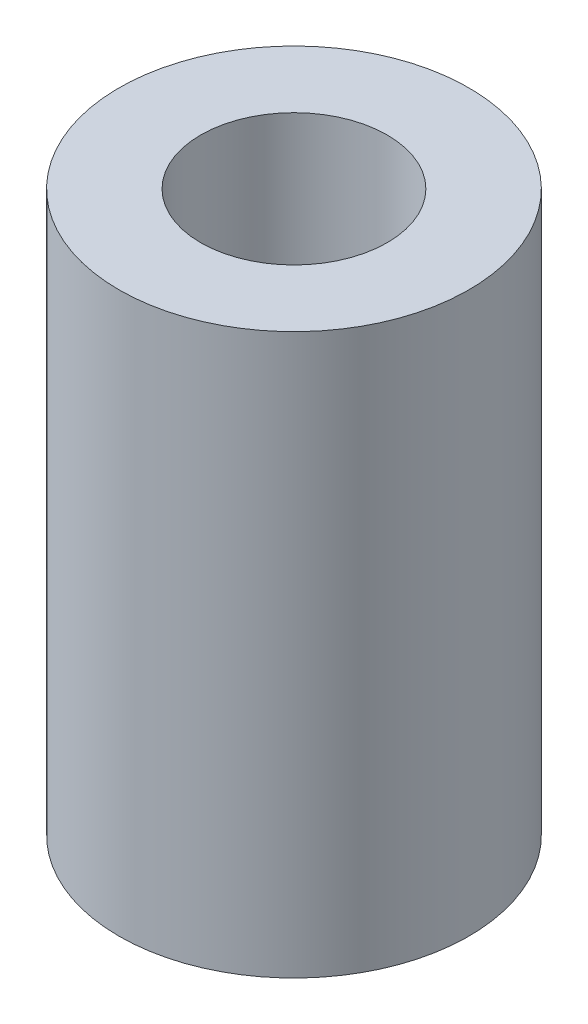
from build123d import *

# Parameters (mm, degrees)
ESBO_O1_R                = 7.5
ESBO_O1_R_2              = 4
RESSALTO_EXTRUS_O1_DEPTH = 24


with BuildPart() as part:
    # Esboço1 → Ressalto-extrusão1 (new body)
    with BuildSketch(Plane(origin=(0, 0, 0), x_dir=(1, 0, 0), z_dir=(0, 1, 0))):
        Circle(ESBO_O1_R)
        Circle(ESBO_O1_R_2, mode=Mode.SUBTRACT)
    extrude(amount=RESSALTO_EXTRUS_O1_DEPTH)


solid = part.part
